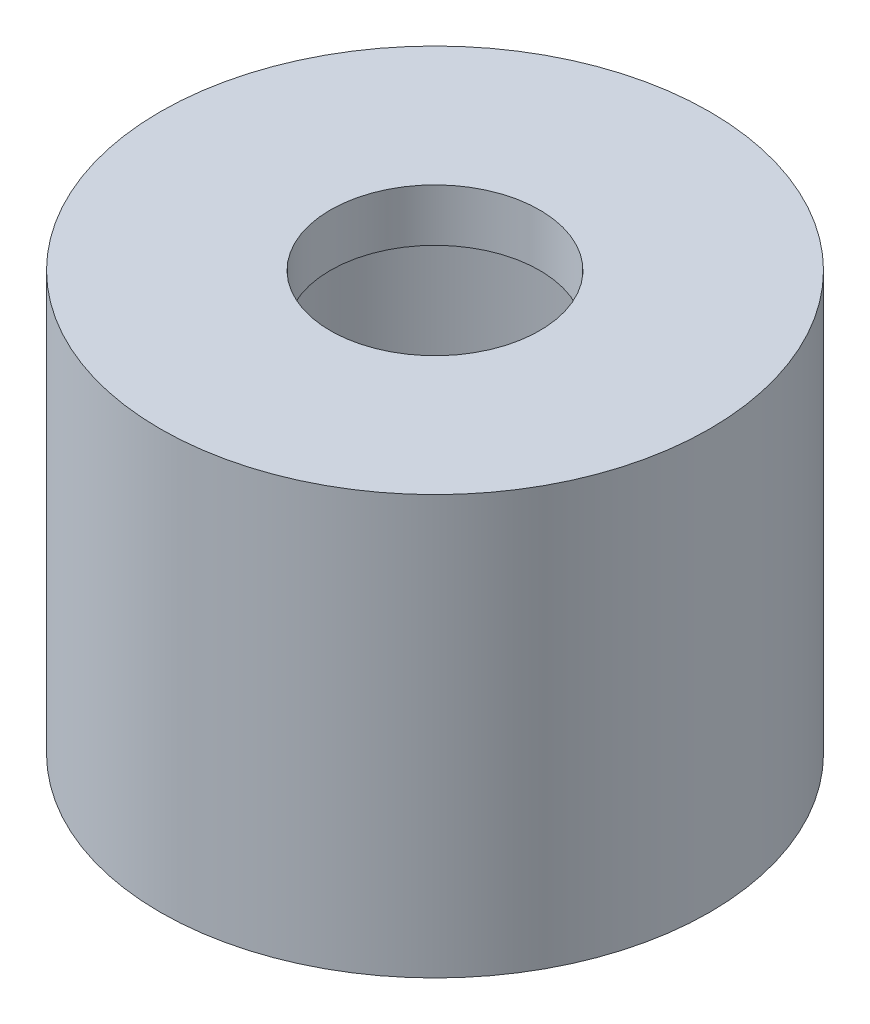
from build123d import *


with BuildPart() as part:
    # Esquisse1 → Révolution1 (revolve)
    with BuildSketch(Plane.XY):
        Polygon((-10.5, 0), (-4, 0), (-4, -2), (-8.5, -2), (-8.5, -16), (-10.5, -16), align=None)
    revolve(axis=Axis((0, 0, 0), (0, -1, 0)))


solid = part.part
